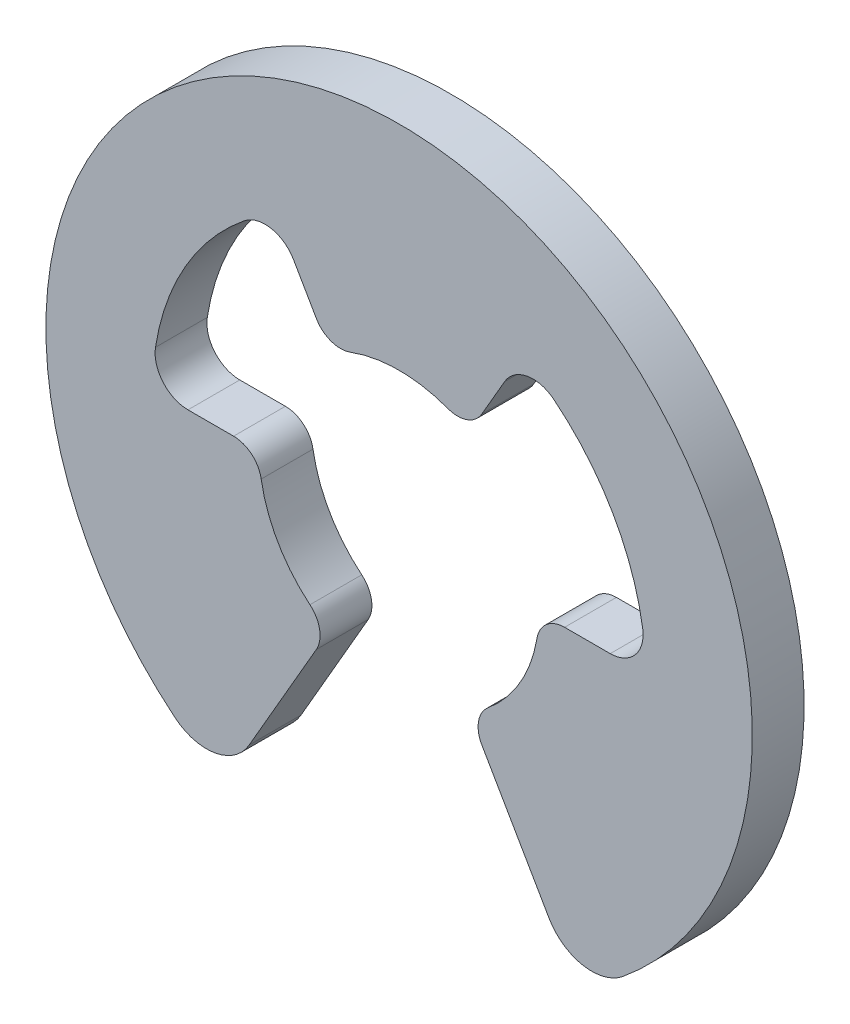
from build123d import *

# Parameters (mm, degrees)
BOSS_EXTRUDE1_DEPTH      = 0.34925
BOSS_EXTRUDE1_DEPTH_BACK = 0.34925


with BuildPart() as part:
    # Sketch1 → Boss-Extrude1 (new, two sides: drawn at the far end of the back side and taken through both)
    with BuildSketch(Plane.XY.offset(-BOSS_EXTRUDE1_DEPTH_BACK)):
        with BuildLine():
            Line((-2.021679848, -3.501652213), (-1.115743067, -1.93252368))
            ThreePointArc((-1.115743067, -1.93252368), (-1.071173907, -1.67711486), (-1.20199934, -1.453273886))
            ThreePointArc((-1.20199934, -1.453273886), (-1.633280615, -0.942974991), (-1.859571778, -0.314325))
            ThreePointArc((-1.859571778, -0.314325), (-1.988011035, -0.089106379), (-2.231486133, 0))
            Line((-2.231486133, 0), (-2.846696218, 0))
            ThreePointArc((-2.846696218, 0), (-3.183353585, 0.154933885), (-3.284649475, 0.511419276))
            ThreePointArc((-3.284649475, 0.511419276), (-2.878863303, 1.662112491), (-2.085226839, 2.588880237))
            ThreePointArc((-2.085226839, 2.588880237), (-1.725853483, 2.679398133), (-1.423348109, 2.465311242))
            Line((-1.423348109, 2.465311242), (-1.115743067, 1.93252368))
            ThreePointArc((-1.115743067, 1.93252368), (-0.916837125, 1.766221247), (-0.657572444, 1.767598903))
            ThreePointArc((-0.657572444, 1.767598903), (5e-09, 1.88595), (0.657572454, 1.7675989))
            ThreePointArc((0.657572454, 1.7675989), (0.91683713, 1.766221249), (1.115743067, 1.93252368))
            Line((1.115743067, 1.93252368), (1.423348109, 2.465311242))
            ThreePointArc((1.423348109, 2.465311242), (1.725853437, 2.679398125), (2.085226766, 2.588880295))
            ThreePointArc((2.085226766, 2.588880295), (2.878863291, 1.662112511), (3.284649482, 0.511419231))
            ThreePointArc((3.284649482, 0.511419231), (3.18335357, 0.154933867), (2.846696218, 0))
            Line((2.846696218, 0), (2.231486133, 0))
            ThreePointArc((2.231486133, 0), (1.988011035, -0.089106379), (1.859571778, -0.314325))
            ThreePointArc((1.859571778, -0.314325), (1.63328061, -0.942975), (1.201999324, -1.4532739))
            ThreePointArc((1.201999324, -1.4532739), (1.071173905, -1.67711487), (1.115743067, -1.93252368))
            Line((1.115743067, -1.93252368), (2.021679848, -3.501652213))
            ThreePointArc((2.021679848, -3.501652213), (2.478220137, -3.823295853), (3.018889478, -3.683437602))
            ThreePointArc((3.018889478, -3.683437602), (3.3e-08, 4.7625), (-3.01888953, -3.68343756))
            ThreePointArc((-3.01888953, -3.68343756), (-2.47822017, -3.823295859), (-2.021679848, -3.501652213))
        make_face()
    extrude(amount=BOSS_EXTRUDE1_DEPTH + BOSS_EXTRUDE1_DEPTH_BACK)


solid = part.part
